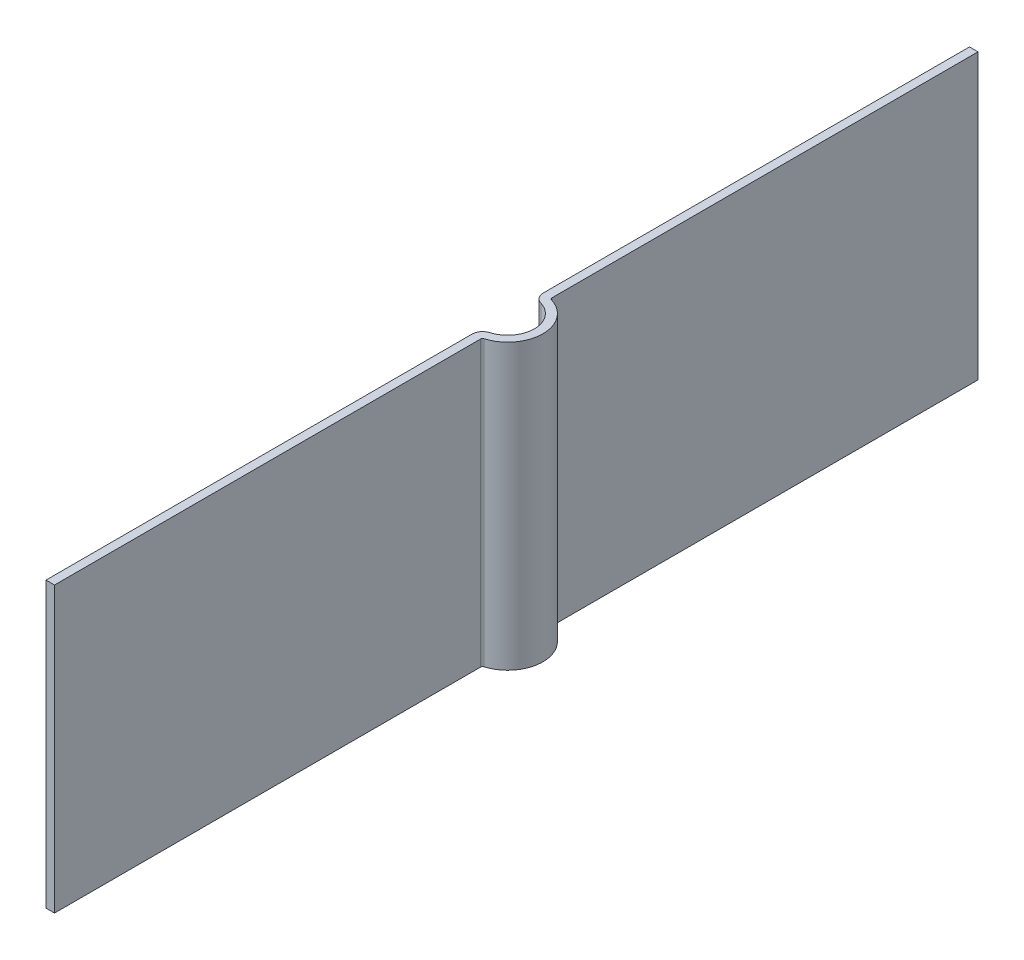
from build123d import *

# Parameters (mm, degrees)
EXTRUDE_THIN1_DEPTH = 4


with BuildPart() as part:
    # Sketch2 → Extrude-Thin1 (new body)
    with BuildSketch(Plane(origin=(0, 0, 0), x_dir=(1, 0, 0), z_dir=(0, 1, 0))):
        with BuildLine():
            Line((0, -6.5), (0, -0.503115295))
            ThreePointArc((0, -0.503115295), (0.029732441, -0.413473149), (0.107142857, -0.359368068))
            ThreePointArc((0.107142857, -0.359368068), (0.375, 0), (0.107142857, 0.359368068))
            ThreePointArc((0.107142857, 0.359368068), (0.029732441, 0.413473149), (0, 0.503115295))
            Line((0, 0.503115295), (0, 6.5))
            Line((0, 6.5), (0.12, 6.5))
            Line((0.12, 6.5), (0.12, 0.503115295))
            ThreePointArc((0.12, 0.503115295), (0.125946488, 0.485186866), (0.141428571, 0.47436585))
            ThreePointArc((0.141428571, 0.47436585), (0.495, 0), (0.141428571, -0.47436585))
            ThreePointArc((0.141428571, -0.47436585), (0.125946488, -0.485186866), (0.12, -0.503115295))
            Line((0.12, -0.503115295), (0.12, -6.5))
            Line((0.12, -6.5), (0, -6.5))
        make_face()
    extrude(amount=EXTRUDE_THIN1_DEPTH)


solid = part.part
